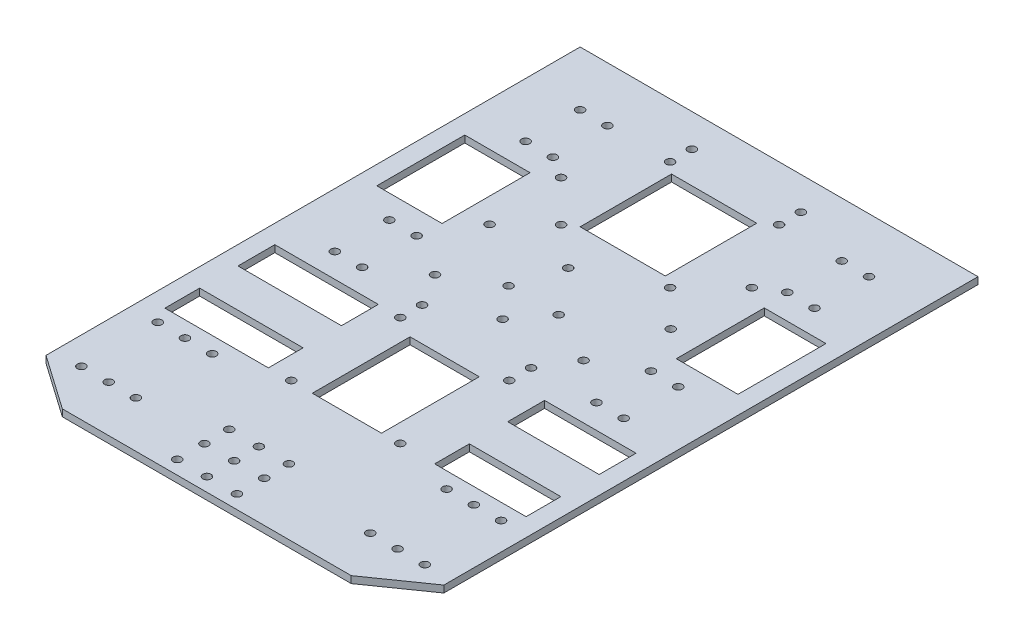
from build123d import *

# Parameters (mm, degrees)
SKETCH1_R           = 1.5
BOSS_EXTRUDE1_DEPTH = 2.54
SKETCH3_W           = 31.262195004
SKETCH3_H           = 33.538767861
SKETCH3_W_2         = 23.950407972
SKETCH3_H_2         = 32.282278018
SKETCH3_W_3         = 37.965776447
SKETCH3_H_3         = 40.338637474
SKETCH3_W_4         = 25.395042547
SKETCH3_H_4         = 35.871060739
SKETCH3_W_5         = 33.559034537
SKETCH3_W_6         = 22.639264221
SKETCH3_R           = 1.5
CUT_EXTRUDE1_DEPTH  = 2.54
SKETCH4_W           = 37.965776447
SKETCH4_H           = 14.057244835
SKETCH4_W_2         = 33.559034537
BOSS_EXTRUDE2_DEPTH = 2.54


with BuildPart() as part:
    # Sketch1 → Boss-Extrude1 (new body)
    with BuildSketch(Plane(origin=(0, 0, 0), x_dir=(1, 0, 0), z_dir=(0, 1, 0))):
        Polygon((86.436432638, 72.445920304), (-59.563567362, 72.445920304), (-59.563567362, -123.554079696), (-39.563567362, -137.554079696), (66.436432638, -137.554079696), (86.436432638, -123.554079696), align=None)
        with Locations((-49.563567362, -120.554079696)):
            Circle(SKETCH1_R, mode=Mode.SUBTRACT)
        with Locations((-39.563567362, -120.554079696)):
            Circle(SKETCH1_R, mode=Mode.SUBTRACT)
        with Locations((-29.563567362, -120.554079696)):
            Circle(SKETCH1_R, mode=Mode.SUBTRACT)
        with Locations((-49.563567362, -92.554079696)):
            Circle(SKETCH1_R, mode=Mode.SUBTRACT)
        with Locations((-39.563567362, -92.554079696)):
            Circle(SKETCH1_R, mode=Mode.SUBTRACT)
        with Locations((-29.563567362, -92.554079696)):
            Circle(SKETCH1_R, mode=Mode.SUBTRACT)
        with Locations((-6.563567362, -86.554079696)):
            Circle(SKETCH1_R, mode=Mode.SUBTRACT)
        with Locations((-39.563567362, -37.554079696)):
            Circle(SKETCH1_R, mode=Mode.SUBTRACT)
        with Locations((-29.563567362, -37.554079696)):
            Circle(SKETCH1_R, mode=Mode.SUBTRACT)
        with Locations((-6.563567362, -46.554079696)):
            Circle(SKETCH1_R, mode=Mode.SUBTRACT)
        with Locations((-6.563567362, -38.554079696)):
            Circle(SKETCH1_R, mode=Mode.SUBTRACT)
        with Locations((33.436432638, -86.554079696)):
            Circle(SKETCH1_R, mode=Mode.SUBTRACT)
        with Locations((56.436432638, -120.554079696)):
            Circle(SKETCH1_R, mode=Mode.SUBTRACT)
        with Locations((66.436432638, -120.554079696)):
            Circle(SKETCH1_R, mode=Mode.SUBTRACT)
        with Locations((76.436432638, -120.554079696)):
            Circle(SKETCH1_R, mode=Mode.SUBTRACT)
        with Locations((56.436432638, -92.554079696)):
            Circle(SKETCH1_R, mode=Mode.SUBTRACT)
        with Locations((66.436432638, -92.554079696)):
            Circle(SKETCH1_R, mode=Mode.SUBTRACT)
        with Locations((76.436432638, -92.554079696)):
            Circle(SKETCH1_R, mode=Mode.SUBTRACT)
        with Locations((33.436432638, -46.554079696)):
            Circle(SKETCH1_R, mode=Mode.SUBTRACT)
        with Locations((33.436432638, -38.554079696)):
            Circle(SKETCH1_R, mode=Mode.SUBTRACT)
        with Locations((56.436432638, -37.554079696)):
            Circle(SKETCH1_R, mode=Mode.SUBTRACT)
        with Locations((66.436432638, -37.554079696)):
            Circle(SKETCH1_R, mode=Mode.SUBTRACT)
        with Locations((-39.563567362, -17.554079696)):
            Circle(SKETCH1_R, mode=Mode.SUBTRACT)
        with Locations((-29.563567362, -17.554079696)):
            Circle(SKETCH1_R, mode=Mode.SUBTRACT)
        with Locations((-13.813567362, -26.554079696)):
            Circle(SKETCH1_R, mode=Mode.SUBTRACT)
        with Locations((-19.813567362, -0.554079696)):
            Circle(SKETCH1_R, mode=Mode.SUBTRACT)
        with Locations((-6.563567362, 12.445920304)):
            Circle(SKETCH1_R, mode=Mode.SUBTRACT)
        with Locations((-39.563567362, 32.445920304)):
            Circle(SKETCH1_R, mode=Mode.SUBTRACT)
        with Locations((-29.563567362, 32.445920304)):
            Circle(SKETCH1_R, mode=Mode.SUBTRACT)
        with Locations((-39.563567362, 52.445920304)):
            Circle(SKETCH1_R, mode=Mode.SUBTRACT)
        with Locations((-29.563567362, 52.445920304)):
            Circle(SKETCH1_R, mode=Mode.SUBTRACT)
        with Locations((-21.563567362, 27.445920304)):
            Circle(SKETCH1_R, mode=Mode.SUBTRACT)
        with Locations((-6.563567362, 52.445920304)):
            Circle(SKETCH1_R, mode=Mode.SUBTRACT)
        with Locations((-6.563567362, 60.445920304)):
            Circle(SKETCH1_R, mode=Mode.SUBTRACT)
        with Locations((40.686432638, -26.554079696)):
            Circle(SKETCH1_R, mode=Mode.SUBTRACT)
        with Locations((46.686432638, -0.554079696)):
            Circle(SKETCH1_R, mode=Mode.SUBTRACT)
        with Locations((33.436432638, 12.445920304)):
            Circle(SKETCH1_R, mode=Mode.SUBTRACT)
        with Locations((56.436432638, -17.554079696)):
            Circle(SKETCH1_R, mode=Mode.SUBTRACT)
        with Locations((66.436432638, -17.554079696)):
            Circle(SKETCH1_R, mode=Mode.SUBTRACT)
        with Locations((48.436432638, 27.445920304)):
            Circle(SKETCH1_R, mode=Mode.SUBTRACT)
        with Locations((33.436432638, 52.445920304)):
            Circle(SKETCH1_R, mode=Mode.SUBTRACT)
        with Locations((33.436432638, 60.445920304)):
            Circle(SKETCH1_R, mode=Mode.SUBTRACT)
        with Locations((56.436432638, 32.445920304)):
            Circle(SKETCH1_R, mode=Mode.SUBTRACT)
        with Locations((66.436432638, 32.445920304)):
            Circle(SKETCH1_R, mode=Mode.SUBTRACT)
        with Locations((56.436432638, 52.445920304)):
            Circle(SKETCH1_R, mode=Mode.SUBTRACT)
        with Locations((66.436432638, 52.445920304)):
            Circle(SKETCH1_R, mode=Mode.SUBTRACT)
    extrude(amount=BOSS_EXTRUDE1_DEPTH)

    # Sketch3 → Cut-Extrude1 (cut)
    with BuildSketch(Plane(origin=(0, 2.54, 0), x_dir=(1, 0, 0), z_dir=(0, 1, 0))):
        with Locations((13.218035303, 32.06539189)):
            Rectangle(SKETCH3_W, SKETCH3_H)
        with Locations((-40.771807944, 7.158059835)):
            Rectangle(SKETCH3_W_2, SKETCH3_H_2)
        with Locations((-33.764123707, -66.570477409)):
            Rectangle(SKETCH3_W_3, SKETCH3_H_3)
        with Locations((14.037654844, -68.804265777)):
            Rectangle(SKETCH3_W_4, SKETCH3_H_4)
        with Locations((63.014708218, -66.570477409)):
            Rectangle(SKETCH3_W_5, SKETCH3_H_3)
        with Locations((68.474593376, 7.158059835)):
            Rectangle(SKETCH3_W_6, SKETCH3_H_2)
        with Locations((3.209707255, -16.593217859)):
            Circle(SKETCH3_R)
        with Locations((12.713373484, -28.278053387)):
            Circle(SKETCH3_R)
        with Locations((21.593848485, -16.593217859)):
            Circle(SKETCH3_R)
        with Locations((8.479175475, 0)):
            Circle(SKETCH3_R)
        with Locations((-2.413062199, -113.470581074)):
            Circle(SKETCH3_R)
        with Locations((8.479175475, -113.470581074)):
            Circle(SKETCH3_R)
        with Locations((19.509289574, -113.470581074)):
            Circle(SKETCH3_R)
        with Locations((19.509289574, -122.554079696)):
            Circle(SKETCH3_R)
        with Locations((-2.413062199, -122.554079696)):
            Circle(SKETCH3_R)
        with Locations((8.479175475, -122.554079696)):
            Circle(SKETCH3_R)
        with Locations((8.479175475, -132.554079696)):
            Circle(SKETCH3_R)
        with Locations((-2.413062199, -132.554079696)):
            Circle(SKETCH3_R)
        with Locations((19.509289574, -132.554079696)):
            Circle(SKETCH3_R)
    extrude(amount=-CUT_EXTRUDE1_DEPTH, mode=Mode.SUBTRACT)

    # Sketch4 → Boss-Extrude2 (add)
    with BuildSketch(Plane(origin=(0, 0, 0), x_dir=(1, 0, 0), z_dir=(0, 1, 0))):
        with Locations((-33.764123707, -66.965043616)):
            Rectangle(SKETCH4_W, SKETCH4_H)
        with Locations((63.014708218, -66.965043616)):
            Rectangle(SKETCH4_W_2, SKETCH4_H)
    extrude(amount=BOSS_EXTRUDE2_DEPTH)


solid = part.part
